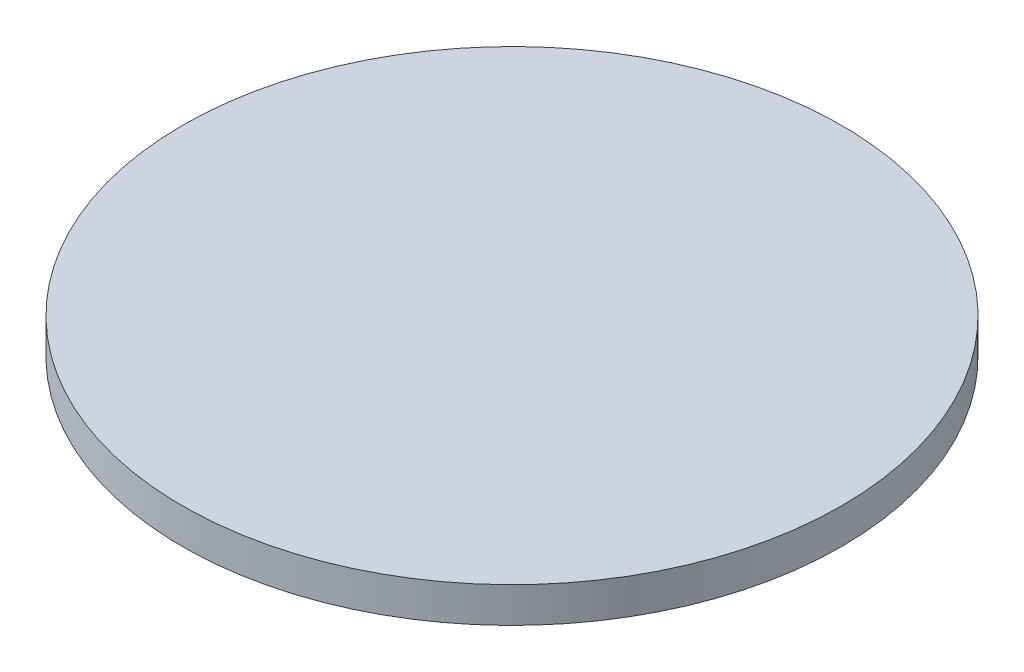
from build123d import *


with BuildPart() as part:
    # Sketch1 → Revolve1 (revolve)
    with BuildSketch(Plane.XY):
        Polygon((0, 0), (-36.5125, 0), (-38.1, -1.5875), (-44.45, -1.5875), (-44.45, 3.175), (0, 3.175), align=None)
    revolve(axis=Axis((0, 3.175, 0), (0, -1, 0)))


solid = part.part
